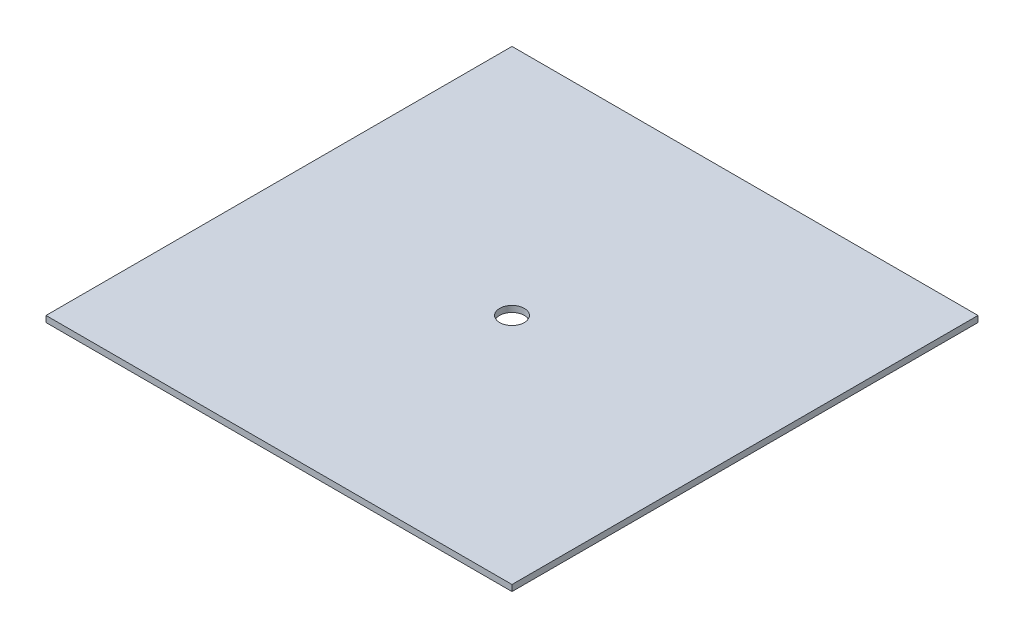
from build123d import *

# Parameters (mm, degrees)
SKETCH1_W           = 60
SKETCH1_H           = 60
SKETCH1_R           = 1.5875
BOSS_EXTRUDE1_DEPTH = 0.79375


with BuildPart() as part:
    # Sketch1 → Boss-Extrude1 (new body)
    with BuildSketch(Plane(origin=(0, 0, 0), x_dir=(1, 0, 0), z_dir=(0, 1, 0))):
        with Locations((47.557337307, 0.540181073)):
            Rectangle(SKETCH1_W, SKETCH1_H)
        with Locations((47.557337307, 0.540181073)):
            Circle(SKETCH1_R, mode=Mode.SUBTRACT)
    extrude(amount=BOSS_EXTRUDE1_DEPTH)


solid = part.part
